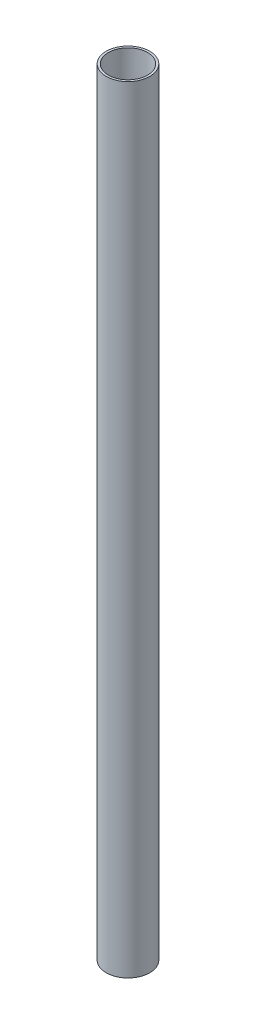
from build123d import *

# Parameters (mm, degrees)
SKETCH1_R           = 2.5
SKETCH1_R_2         = 2.25
BOSS_EXTRUDE1_DEPTH = 89
BOSS_EXTRUDE2_START = -5
SKETCH2_R           = 2.25
BOSS_EXTRUDE2_DEPTH = 66


with BuildPart() as part:
    # Sketch1 → Boss-Extrude1 (new body)
    with BuildSketch(Plane(origin=(0, 0, 0), x_dir=(1, 0, 0), z_dir=(0, 1, 0))):
        Circle(SKETCH1_R)
        Circle(SKETCH1_R_2, mode=Mode.SUBTRACT)
    extrude(amount=BOSS_EXTRUDE1_DEPTH)


with BuildPart() as body_2:
    # Sketch2 → Boss-Extrude2 (new body)
    with BuildSketch(Plane(origin=(0, 89, 0), x_dir=(1, 0, 0), z_dir=(0, 1, 0)).offset(BOSS_EXTRUDE2_START)):
        Circle(SKETCH2_R)
    extrude(amount=-BOSS_EXTRUDE2_DEPTH)


solid = Compound([part.part, body_2.part])
